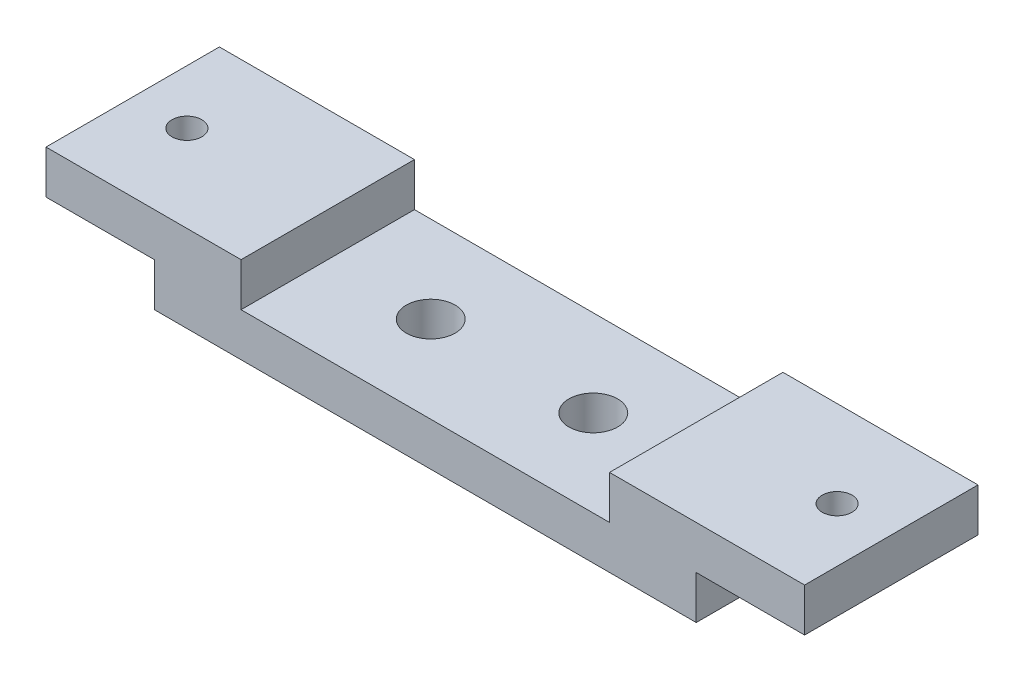
from build123d import *

# Parameters (mm, degrees)
AUFSATZ_LINEAR_AUSTRAGEN1_DEPTH  = 32
F_9_0_9_DURCHMESSER_BOHRUNG1_D   = 9
F_5_5_5_5_DURCHMESSER_BOHRUNG1_D = 5.5


with BuildPart() as part:
    # Skizze1 → Aufsatz-Linear austragen1 (new body)
    with BuildSketch(Plane.XY):
        Polygon((-70, 16), (-34, 16), (-34, 8), (34, 8), (34, 16), (70, 16), (70, 8), (50, 8), (50, 0), (-50, 0), (-50, 8), (-70, 8), align=None)
    extrude(amount=AUFSATZ_LINEAR_AUSTRAGEN1_DEPTH)

    # Ø9.0 (9) Durchmesser Bohrung1 (through all)
    with Locations(Plane(origin=(15, 8, 16), x_dir=(0, 0, 1), z_dir=(0, 1, 0))):
        with Locations((0, 0), (0, -30)):
            Hole(F_9_0_9_DURCHMESSER_BOHRUNG1_D / 2)

    # Ø5.5 (5.5) Durchmesser Bohrung1 (through all)
    with Locations(Plane(origin=(-60, 8, 16), x_dir=(0, 0, -1), z_dir=(0, -1, 0))):
        with Locations((0, 0), (0, 120)):
            Hole(F_5_5_5_5_DURCHMESSER_BOHRUNG1_D / 2)


solid = part.part
